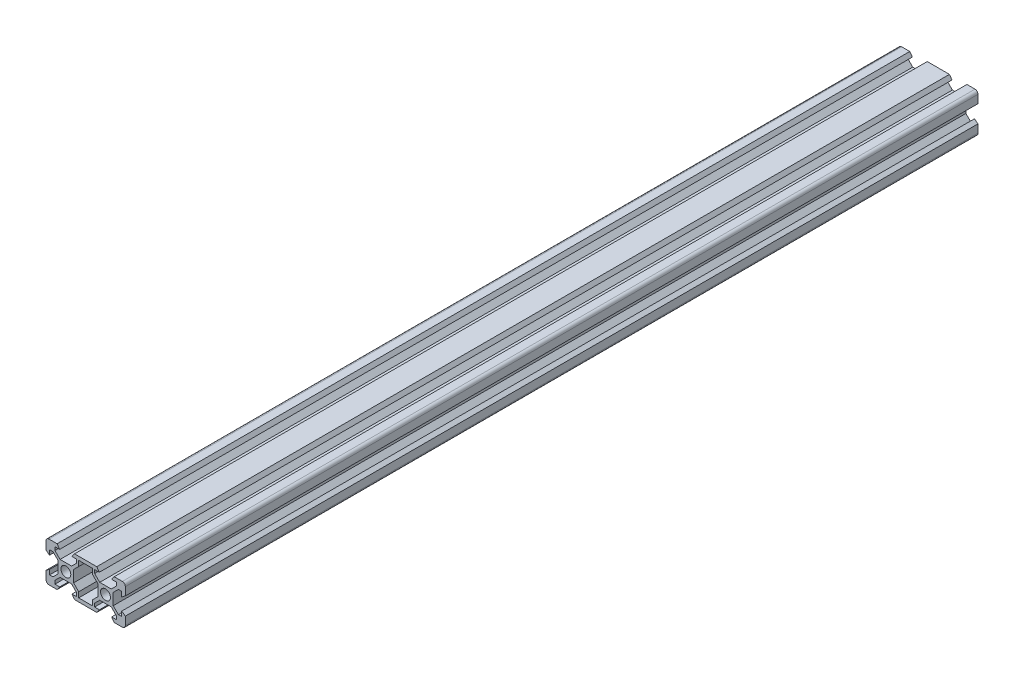
from build123d import *

# Parameters (mm, degrees)
SKETCH_1_R      = 2.5
EXTRUDE_1_DEPTH = 430


with BuildPart() as part:
    # 草图1 → 凸台-拉伸1 (new body)
    with BuildSketch(Plane.XY):
        with BuildLine():
            Line((14.8, 34.821428571), (18.9, 34.821428571))
            Line((18.9, 34.821428571), (20.2, 33.021428571))
            Line((20.2, 33.021428571), (17.8, 33.021428571))
            Line((17.8, 33.021428571), (17.8, 31.311378065))
            Line((17.8, 31.311378065), (20.389949494, 28.721428571))
            Line((20.389949494, 28.721428571), (26.210050506, 28.721428571))
            Line((26.210050506, 28.721428571), (28.8, 31.311378065))
            Line((28.8, 31.311378065), (28.8, 33.021428571))
            Line((28.8, 33.021428571), (26.4, 33.021428571))
            Line((26.4, 33.021428571), (27.7, 34.821428571))
            Line((27.7, 34.821428571), (38.9, 34.821428571))
            Line((38.9, 34.821428571), (40.2, 33.021428571))
            Line((40.2, 33.021428571), (37.8, 33.021428571))
            Line((37.8, 33.021428571), (37.8, 31.311378065))
            Line((37.8, 31.311378065), (40.389949494, 28.721428571))
            Line((40.389949494, 28.721428571), (46.210050506, 28.721428571))
            Line((46.210050506, 28.721428571), (48.8, 31.311378065))
            Line((48.8, 31.311378065), (48.8, 33.021428571))
            Line((48.8, 33.021428571), (46.4, 33.021428571))
            Line((46.4, 33.021428571), (47.7, 34.821428571))
            Line((47.7, 34.821428571), (51.8, 34.821428571))
            ThreePointArc((51.8, 34.821428571), (52.860660172, 34.382088743), (53.3, 33.321428571))
            Line((53.3, 33.321428571), (53.3, 29.221428571))
            Line((53.3, 29.221428571), (51.5, 27.921428571))
            Line((51.5, 27.921428571), (51.5, 30.321428571))
            Line((51.5, 30.321428571), (49.789949494, 30.321428571))
            Line((49.789949494, 30.321428571), (47.2, 27.731479078))
            Line((47.2, 27.731479078), (47.2, 21.911378065))
            Line((47.2, 21.911378065), (49.789949494, 19.321428571))
            Line((49.789949494, 19.321428571), (51.5, 19.321428571))
            Line((51.5, 19.321428571), (51.5, 21.721428571))
            Line((51.5, 21.721428571), (53.3, 20.421428571))
            Line((53.3, 20.421428571), (53.3, 16.321428571))
            ThreePointArc((53.3, 16.321428571), (52.860660172, 15.2607684), (51.8, 14.821428571))
            Line((51.8, 14.821428571), (47.7, 14.821428571))
            Line((47.7, 14.821428571), (46.4, 16.621428571))
            Line((46.4, 16.621428571), (48.8, 16.621428571))
            Line((48.8, 16.621428571), (48.8, 18.331479078))
            Line((48.8, 18.331479078), (46.210050506, 20.921428571))
            Line((46.210050506, 20.921428571), (40.389949494, 20.921428571))
            Line((40.389949494, 20.921428571), (37.8, 18.331479078))
            Line((37.8, 18.331479078), (37.8, 16.621428571))
            Line((37.8, 16.621428571), (40.2, 16.621428571))
            Line((40.2, 16.621428571), (38.9, 14.821428571))
            Line((38.9, 14.821428571), (27.7, 14.821428571))
            Line((27.7, 14.821428571), (26.4, 16.621428571))
            Line((26.4, 16.621428571), (28.8, 16.621428571))
            Line((28.8, 16.621428571), (28.8, 18.331479078))
            Line((28.8, 18.331479078), (26.210050506, 20.921428571))
            Line((26.210050506, 20.921428571), (20.389949494, 20.921428571))
            Line((20.389949494, 20.921428571), (17.8, 18.331479078))
            Line((17.8, 18.331479078), (17.8, 16.621428571))
            Line((17.8, 16.621428571), (20.2, 16.621428571))
            Line((20.2, 16.621428571), (18.9, 14.821428571))
            Line((18.9, 14.821428571), (14.8, 14.821428571))
            ThreePointArc((14.8, 14.821428571), (13.739339828, 15.2607684), (13.3, 16.321428571))
            Line((13.3, 16.321428571), (13.3, 20.421428571))
            Line((13.3, 20.421428571), (15.1, 21.721428571))
            Line((15.1, 21.721428571), (15.1, 19.321428571))
            Line((15.1, 19.321428571), (16.810050506, 19.321428571))
            Line((16.810050506, 19.321428571), (19.4, 21.911378065))
            Line((19.4, 21.911378065), (19.4, 27.731479078))
            Line((19.4, 27.731479078), (16.810050506, 30.321428571))
            Line((16.810050506, 30.321428571), (15.1, 30.321428571))
            Line((15.1, 30.321428571), (15.1, 27.921428571))
            Line((15.1, 27.921428571), (13.3, 29.221428571))
            Line((13.3, 29.221428571), (13.3, 33.321428571))
            ThreePointArc((13.3, 33.321428571), (13.739339828, 34.382088743), (14.8, 34.821428571))
        make_face()
        with Locations((23.3, 24.821428571)):
            Circle(SKETCH_1_R, mode=Mode.SUBTRACT)
        with Locations((43.3, 24.821428571)):
            Circle(SKETCH_1_R, mode=Mode.SUBTRACT)
        Polygon((27.2, 27.731479078), (29.789949494, 30.321428571), (29.789949494, 33.021428571), (36.810050506, 33.021428571), (36.810050506, 30.321428571), (39.4, 27.731479078), (39.4, 21.911378065), (36.810050506, 19.321428571), (36.810050506, 16.621428571), (29.789949494, 16.621428571), (29.789949494, 19.321428571), (27.2, 21.911378065), align=None, mode=Mode.SUBTRACT)
    extrude(amount=EXTRUDE_1_DEPTH)


solid = part.part
